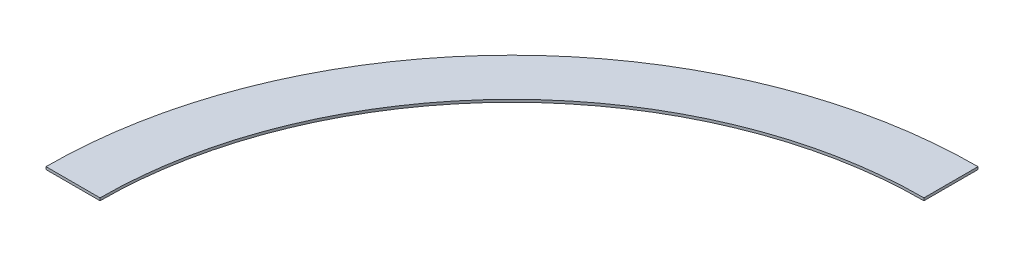
from build123d import *

# Parameters (mm, degrees)
Y_KSEKLIK_EKSTR_ZYON1_DEPTH = 1


with BuildPart() as part:
    # Çizim1 → Yükseklik-Ekstrüzyon1 (new body)
    with BuildSketch(Plane(origin=(0, 0, 0), x_dir=(1, 0, 0), z_dir=(0, 1, 0))):
        with BuildLine():
            Line((0, 160), (0, 181))
            ThreePointArc((0, 181), (-127.986327395, 127.986327395), (-181, 0))
            Line((-181, 0), (-160, 0))
            ThreePointArc((-160, 0), (-113.13708499, 113.13708499), (0, 160))
        make_face()
    extrude(amount=Y_KSEKLIK_EKSTR_ZYON1_DEPTH)


solid = part.part
